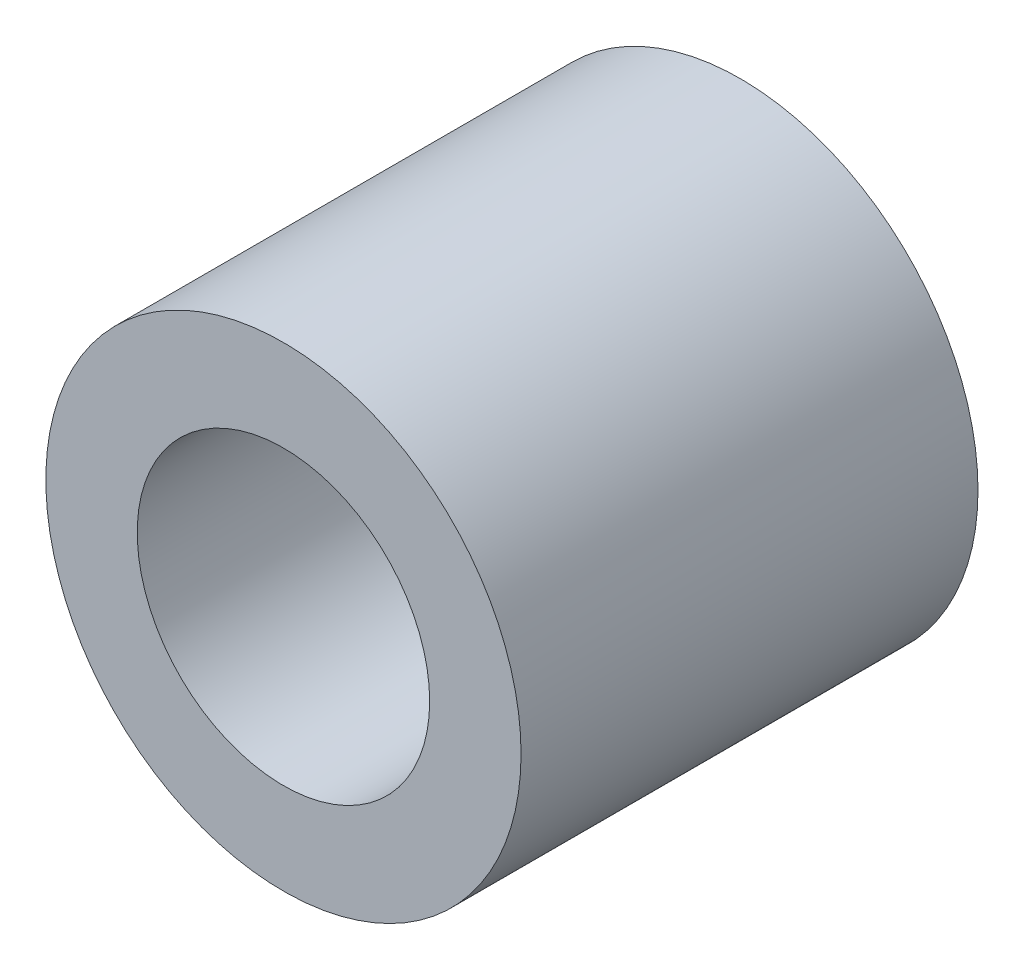
from build123d import *

# Parameters (mm, degrees)
SKETCH1_R                = 2.6
BOSS_EXTRUDE1_DEPTH      = 5
M3_CLEARANCE_HOLE1_D     = 3.2
M3_CLEARANCE_HOLE1_DEPTH = 7
M3_CLEARANCE_HOLE1_TIP   = 0.96137699


with BuildPart() as part:
    # Sketch1 → Boss-Extrude1 (new body)
    with BuildSketch(Plane.XY):
        with Locations((1.45, 331)):
            Circle(SKETCH1_R)
    extrude(amount=BOSS_EXTRUDE1_DEPTH)

    # M3 Clearance Hole1
    with Locations(Plane.XY.offset(5)):
        with Locations((1.45, 331)):
            Hole(M3_CLEARANCE_HOLE1_D / 2, depth=M3_CLEARANCE_HOLE1_DEPTH)
            with Locations((0, 0, -(M3_CLEARANCE_HOLE1_DEPTH + M3_CLEARANCE_HOLE1_TIP / 2))):  # 118° drill point
                Cone(0, M3_CLEARANCE_HOLE1_D / 2, M3_CLEARANCE_HOLE1_TIP, mode=Mode.SUBTRACT)


solid = part.part
